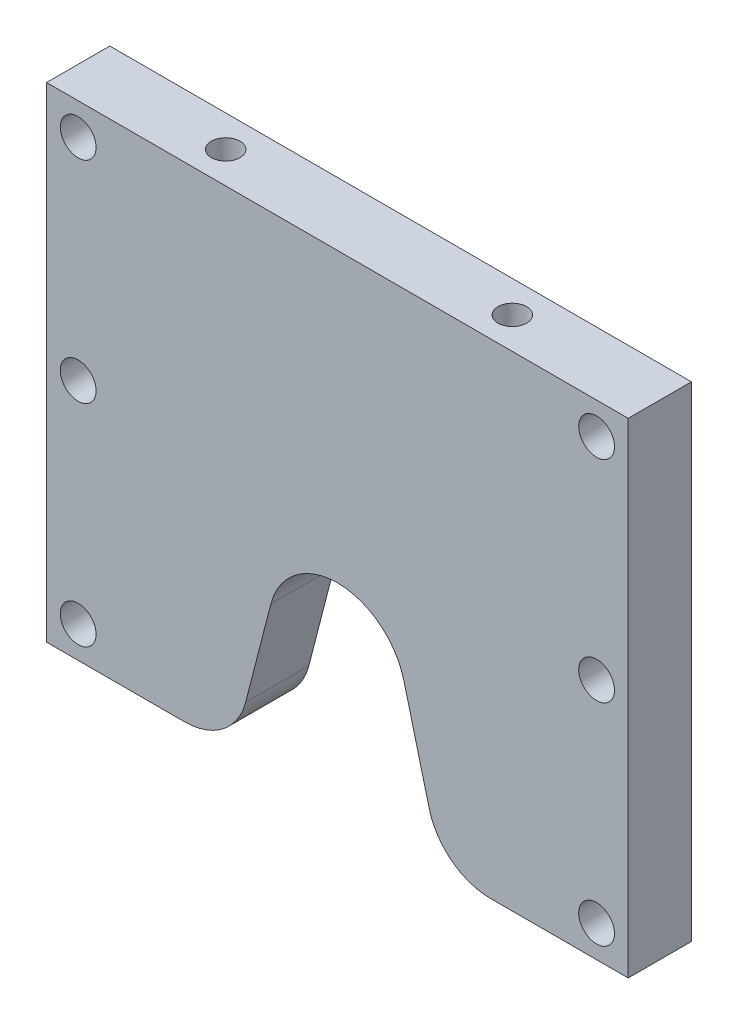
from build123d import *

# Parameters (mm, degrees)
CROQUIS1_R                = 4.25
SALIENTE_EXTRUIR1_DEPTH   = 7.5
CROQUIS2_R                = 6.5
CORTAR_EXTRUIR1_DEPTH     = 8
TALADRO_ROSCADO_M81_D     = 6.8
TALADRO_ROSCADO_M81_DEPTH = 20
TALADRO_ROSCADO_M81_TIP   = 2.042926105


with BuildPart() as part:
    # Croquis1 → Saliente-Extruir1 (new body, symmetric)
    with BuildSketch(Plane.XY):
        with BuildLine():
            Line((69, -57.5), (36.3, -57.5))
            ThreePointArc((36.3, -57.5), (27.113751898, -54.358028749), (21.775894122, -46.248379441))
            Line((21.775894122, -46.248379441), (15.782861721, -23.026761008))
            ThreePointArc((15.782861721, -23.026761008), (0, -10.8), (-15.782861721, -23.026761008))
            Line((-15.782861721, -23.026761008), (-21.775894122, -46.248379441))
            ThreePointArc((-21.775894122, -46.248379441), (-27.113751898, -54.358028749), (-36.3, -57.5))
            Line((-36.3, -57.5), (-69, -57.5))
            Line((-69, -57.5), (-69, 57.5))
            Line((-69, 57.5), (69, 57.5))
            Line((69, 57.5), (69, -57.5))
        make_face()
        with Locations((-61.5, 50)):
            Circle(CROQUIS1_R, mode=Mode.SUBTRACT)
        with Locations((-61.5, 0)):
            Circle(CROQUIS1_R, mode=Mode.SUBTRACT)
        with Locations((-61.5, -50)):
            Circle(CROQUIS1_R, mode=Mode.SUBTRACT)
        with Locations((61.5, 50)):
            Circle(CROQUIS1_R, mode=Mode.SUBTRACT)
        with Locations((61.5, 0)):
            Circle(CROQUIS1_R, mode=Mode.SUBTRACT)
        with Locations((61.5, -50)):
            Circle(CROQUIS1_R, mode=Mode.SUBTRACT)
    extrude(amount=SALIENTE_EXTRUIR1_DEPTH, both=True)

    # Croquis2 → Cortar-Extruir1 (cut)
    with BuildSketch(Plane(origin=(0, 0, -7.5), x_dir=(-1, 0, 0), z_dir=(0, 0, -1))):
        with Locations((-61.5, 50)):
            Circle(CROQUIS2_R)
        with Locations((-61.5, 0)):
            Circle(CROQUIS2_R)
        with Locations((-61.5, -50)):
            Circle(CROQUIS2_R)
        with Locations((61.5, 50)):
            Circle(CROQUIS2_R)
        with Locations((61.5, 0)):
            Circle(CROQUIS2_R)
        with Locations((61.5, -50)):
            Circle(CROQUIS2_R)
    extrude(amount=-CORTAR_EXTRUIR1_DEPTH, mode=Mode.SUBTRACT)

    # Taladro roscado M81
    with Locations(Plane(origin=(0, 57.5, 0), x_dir=(-1, 0, 0), z_dir=(0, 1, 0))):
        with Locations((34, 0), (-34, 0)):
            Hole(TALADRO_ROSCADO_M81_D / 2, depth=TALADRO_ROSCADO_M81_DEPTH)
            with Locations((0, 0, -(TALADRO_ROSCADO_M81_DEPTH + TALADRO_ROSCADO_M81_TIP / 2))):  # 118° drill point
                Cone(0, TALADRO_ROSCADO_M81_D / 2, TALADRO_ROSCADO_M81_TIP, mode=Mode.SUBTRACT)


solid = part.part
